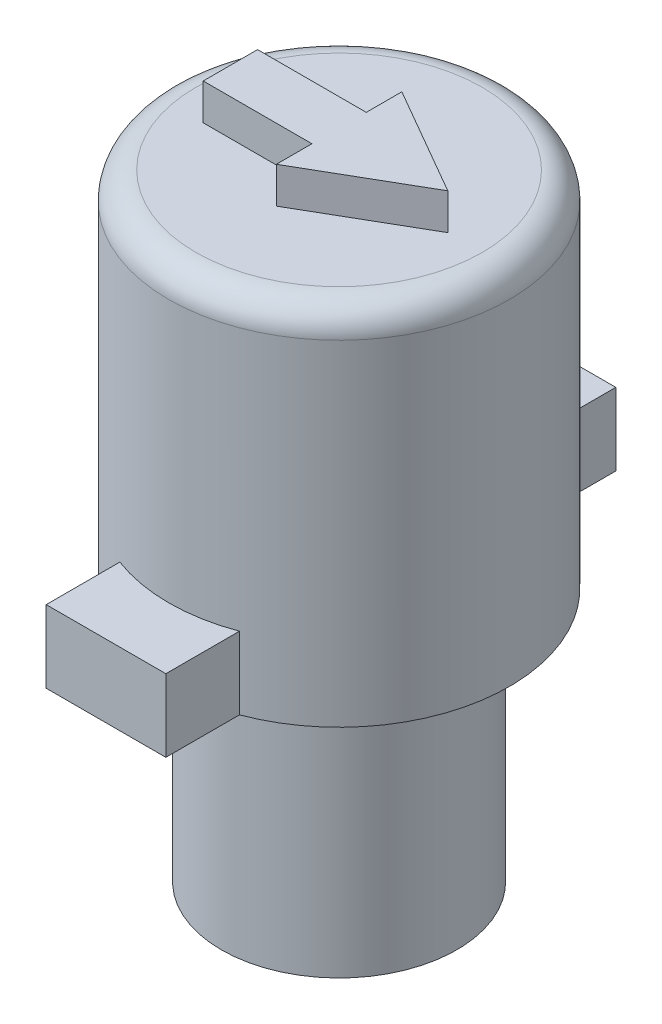
from build123d import *

# Parameters (mm, degrees)
SKETCH1_R           = 3.25
BOSS_EXTRUDE1_DEPTH = 7.018
SKETCH6_R           = 4.7
BOSS_EXTRUDE2_DEPTH = 10
FILLET1_R           = 0.75
BOSS_EXTRUDE3_DEPTH = 1
BOSS_EXTRUDE4_DEPTH = 2


with BuildPart() as part:
    # Sketch1 → Boss-Extrude1 (new body)
    with BuildSketch(Plane(origin=(0, 0, 0), x_dir=(1, 0, 0), z_dir=(0, 1, 0))):
        Circle(SKETCH1_R)
    extrude(amount=BOSS_EXTRUDE1_DEPTH)

    # Sketch6 → Boss-Extrude2 (add)
    with BuildSketch(Plane(origin=(0, 7.018, 0), x_dir=(1, 0, 0), z_dir=(0, 1, 0))):
        Circle(SKETCH6_R)
    extrude(amount=BOSS_EXTRUDE2_DEPTH)

    # Fillet1
    fillet1_edges = [part.edges().sort_by_distance(p)[0] for p in [
        (-4.7, 17.018, 0),
    ]]
    fillet(fillet1_edges, radius=FILLET1_R)

    # Sketch8 → Boss-Extrude3 (add)
    with BuildSketch(Plane(origin=(0, 17.018, 0), x_dir=(1, 0, 0), z_dir=(0, 1, 0))):
        Polygon((0, 0.75), (-3, 0.75), (-3, -0.75), (0, -0.75), (0, -1.732050808), (3, 0), (0, 1.732050808), align=None)
    extrude(amount=BOSS_EXTRUDE3_DEPTH)

    # Sketch9 → Boss-Extrude4 (add)
    with BuildSketch(Plane.XZ.offset(-7.018)):
        with BuildLine():
            Line((-1.651, 4.400477133), (-1.651, 6.432477133))
            Line((-1.651, 6.432477133), (1.651, 6.432477133))
            Line((1.651, 6.432477133), (1.651, 4.400477133))
            ThreePointArc((1.651, 4.400477133), (0, 4.7), (-1.651, 4.400477133))
        make_face()
        with BuildLine():
            Line((-1.016, -4.588871757), (-1.016, -6.620871757))
            Line((-1.016, -6.620871757), (1.016, -6.620871757))
            Line((1.016, -6.620871757), (1.016, -4.588871757))
            ThreePointArc((1.016, -4.588871757), (0, -4.7), (-1.016, -4.588871757))
        make_face()
    extrude(amount=-BOSS_EXTRUDE4_DEPTH)


solid = part.part
